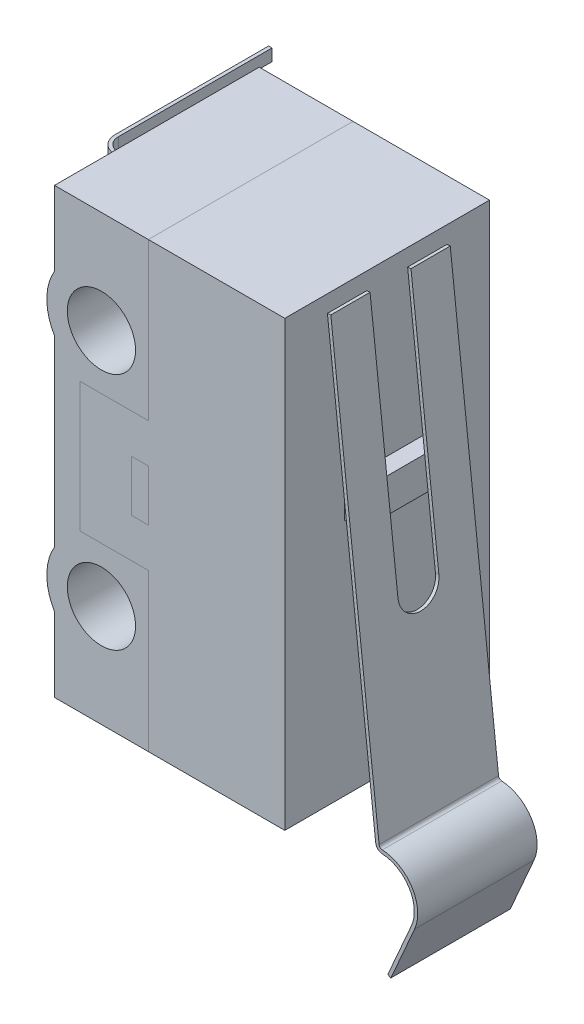
from build123d import *

# Parameters (mm, degrees)
ESQUISSE1_W                    = 0.5
ESQUISSE1_H                    = 1.5
BOSS_EXTRU_1_DEPTH             = 3
ESQUISSE2_R                    = 1
BOSS_EXTRU_2_DEPTH             = 6
ESQUISSE2_W                    = 0.5
ESQUISSE2_H                    = 1.5
BOSS_EXTRU_2_2_DEPTH           = 6
ESQUISSE3_W                    = 0.5
ESQUISSE3_H                    = 1
BOSS_EXTRU_3_DEPTH             = 1.25
BOSS_EXTRU_4_DEPTH             = 1.75
ENL_V_MAT_EXTRU_1_DEPTH        = 0.1
BOSS_EXTRU_5_DEPTH             = 0.175
R_P_TITION_LIN_AIRE1_COUNT     = 2
R_P_TITION_LIN_AIRE1_PITCH     = 5
R_P_TITION_LIN_AIRE1_COL_COUNT = 2
R_P_TITION_LIN_AIRE1_COL_PITCH = 5


with BuildPart() as part:
    # Esquisse1 → Boss.-Extru.1 (new, symmetric)
    with BuildSketch(Plane.XY):
        Polygon((-4, -1.9), (-4, -6.5), (0, -6.5), (0, 6.5), (-4, 6.5), (-4, 1.9), (-6, 1.9), (-6, -1.9), align=None)
        with Locations((-4.25, 0)):
            Rectangle(ESQUISSE1_W, ESQUISSE1_H, mode=Mode.SUBTRACT)
    extrude(amount=BOSS_EXTRU_1_DEPTH, both=True)


with BuildPart() as body_2:
    # Esquisse2 → Boss.-Extru.2 (new body)
    with BuildSketch(Plane.XY.offset(3)):
        with BuildLine():
            Line((-4, 6.5), (-6.75, 6.5))
            Line((-6.75, 6.5), (-6.75, 4.318153409))
            ThreePointArc((-6.75, 4.318153409), (-6.975, 3.5), (-6.75, 2.681846591))
            Line((-6.75, 2.681846591), (-6.75, -2.681846591))
            ThreePointArc((-6.75, -2.681846591), (-6.975, -3.5), (-6.75, -4.318153409))
            Line((-6.75, -4.318153409), (-6.75, -6.5))
            Line((-6.75, -6.5), (-4, -6.5))
            Line((-4, -6.5), (-4, -1.9))
            Line((-4, -1.9), (-6, -1.9))
            Line((-6, -1.9), (-6, 1.9))
            Line((-6, 1.9), (-4, 1.9))
            Line((-4, 1.9), (-4, 6.5))
        make_face()
        with Locations((-5.375, 3.5)):
            Circle(ESQUISSE2_R, mode=Mode.SUBTRACT)
        with Locations((-5.375, -3.5)):
            Circle(ESQUISSE2_R, mode=Mode.SUBTRACT)
    extrude(amount=-BOSS_EXTRU_2_DEPTH)


with BuildPart() as body_3:
    # Esquisse2 → Boss.-Extru.2 2 (new body)
    with BuildSketch(Plane.XY.offset(3)):
        with Locations((-4.25, 0)):
            Rectangle(ESQUISSE2_W, ESQUISSE2_H)
    extrude(amount=-BOSS_EXTRU_2_2_DEPTH)


with BuildPart() as body_4:
    # Esquisse3 → Boss.-Extru.3 (new, symmetric)
    with BuildSketch(Plane.XY):
        with Locations((0.25, 1)):
            Rectangle(ESQUISSE3_W, ESQUISSE3_H)
    extrude(amount=BOSS_EXTRU_3_DEPTH, both=True)


with BuildPart() as body_5:
    # Esquisse4 → Boss.-Extru.4 (new, symmetric)
    with BuildSketch(Plane.XY):
        with BuildLine():
            Line((0, 6), (1.415377021, -6.738393192))
            ThreePointArc((1.415377021, -6.738393192), (1.476592169, -6.861485419), (1.602801701, -6.915984453))
            ThreePointArc((1.602801701, -6.915984453), (2.398287719, -7.391231624), (2.461985691, -8.315677646))
            Line((2.461985691, -8.315677646), (1.766904417, -9.902139755))
            Line((1.766904417, -9.902139755), (1.85849885, -9.942270291))
            Line((1.85849885, -9.942270291), (2.553580123, -8.355808182))
            ThreePointArc((2.553580123, -8.355808182), (2.483512355, -7.338917558), (1.608477735, -6.81614567))
            ThreePointArc((1.608477735, -6.81614567), (1.545372968, -6.788896153), (1.514765395, -6.727350039))
            Line((1.514765395, -6.727350039), (0.099388373, 6.011043153))
            Line((0.099388373, 6.011043153), (0, 6))
        make_face()
    extrude(amount=BOSS_EXTRU_4_DEPTH, both=True)

    # Esquisse5 → Enlèv. mat.-Extru.1 (cut)
    with BuildSketch(Plane(origin=(0.757924959, 0.084213884, 0), x_dir=(0, 0, -1), z_dir=(0.9938837346736189, 0.11043152607484652, 0))):
        with BuildLine():
            Line((-0.6, 5.963302408), (-0.6, -1.436697592))
            ThreePointArc((-0.6, -1.436697592), (0, -2.036697592), (0.6, -1.436697592))
            Line((0.6, -1.436697592), (0.6, 5.963302408))
            Line((0.6, 5.963302408), (-0.6, 5.963302408))
        make_face()
    extrude(amount=-ENL_V_MAT_EXTRU_1_DEPTH, mode=Mode.SUBTRACT)


with BuildPart() as body_6:
    # Esquisse6 → Boss.-Extru.5 (new, symmetric)
    with BuildSketch(Plane(origin=(0, 0, 0), x_dir=(1, 0, 0), z_dir=(0, 1, 0))):
        with BuildLine():
            Line((-6.975, 0), (-7.975, 0))
            ThreePointArc((-7.975, 0), (-8.328553391, 0.146446609), (-8.475, 0.5))
            Line((-8.475, 0.5), (-8.475, 5))
            Line((-8.475, 5), (-8.375, 5))
            Line((-8.375, 5), (-8.375, 0.5))
            ThreePointArc((-8.375, 0.5), (-8.257842712, 0.217157288), (-7.975, 0.1))
            Line((-7.975, 0.1), (-6.975, 0.1))
            Line((-6.975, 0.1), (-6.75, 0.1))
            Line((-6.75, 0.1), (-6.75, 0))
            Line((-6.75, 0), (-6.975, 0))
        make_face()
    boss_extru_5 = extrude(amount=BOSS_EXTRU_5_DEPTH, both=True)


with BuildPart() as body_2_1:
    add(body_2.part)

    # Répétition linéaire1: Boss.-Extru.5 ×2
    with Locations(*[(0, -i * R_P_TITION_LIN_AIRE1_PITCH, 0) for i in range(1, R_P_TITION_LIN_AIRE1_COUNT)]):
        add(boss_extru_5)

    # Répétition linéaire1 col: Boss.-Extru.5 ×2
    with Locations(*[(0, i * R_P_TITION_LIN_AIRE1_COL_PITCH, 0) for i in range(1, R_P_TITION_LIN_AIRE1_COL_COUNT)]):
        add(boss_extru_5)

    # Répétition linéaire1 col and its seed as: union body 6
    add(body_6.part)


solid = Compound([part.part, body_3.part, body_4.part, body_5.part, body_2_1.part])
